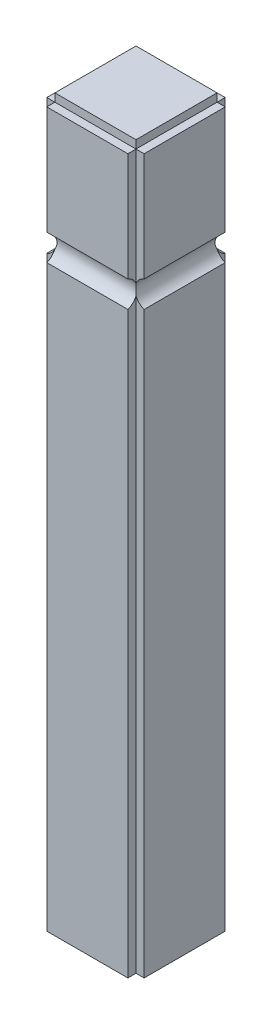
from build123d import *

# Parameters (mm, degrees)
SKETCH_4_W               = 180
SKETCH_4_H               = 180
EXTRUDE_1_DEPTH          = 1320
SKETCH_5_W               = 15
SKETCH_5_H               = 15
CUT_EXTRUDE_1_DEPTH      = 1320
CUT_EXTRUDE_2_DEPTH      = 1
CUT_EXTRUDE_2_DEPTH_BACK = 181
CUT_EXTRUDE_3_DEPTH      = 181
SKETCH_8_W               = 150
SKETCH_8_H               = 150
EXTRUDE_2_DEPTH          = 15


with BuildPart() as part:
    # 草图4 → 凸台-拉伸1 (new body)
    with BuildSketch(Plane(origin=(0, 0, 0), x_dir=(1, 0, 0), z_dir=(0, 1, 0))):
        with Locations((90, 90)):
            Rectangle(SKETCH_4_W, SKETCH_4_H)
    extrude(amount=-EXTRUDE_1_DEPTH)

    # 草图5 → 切除-拉伸1 (cut)
    with BuildSketch(Plane(origin=(0, 0, 0), x_dir=(1, 0, 0), z_dir=(0, 1, 0))):
        with Locations((7.5, 172.5)):
            Rectangle(SKETCH_5_W, SKETCH_5_H)
        with Locations((7.5, 7.5)):
            Rectangle(SKETCH_5_W, SKETCH_5_H)
        with Locations((172.5, 172.5)):
            Rectangle(SKETCH_5_W, SKETCH_5_H)
        with Locations((172.5, 7.5)):
            Rectangle(SKETCH_5_W, SKETCH_5_H)
    extrude(amount=-CUT_EXTRUDE_1_DEPTH, mode=Mode.SUBTRACT)

    # 草图6 → 切除-拉伸2 (cut, two sides)
    with BuildSketch(Plane.XY) as cut_extrude_2_sk:
        with BuildLine():
            Line((0, -200.607378165), (0, -249.392621835))
            ThreePointArc((0, -249.392621835), (17, -225), (0, -200.607378165))
        make_face()
        with BuildLine():
            Line((180, -200.607378165), (180, -249.392621835))
            ThreePointArc((180, -249.392621835), (163, -225), (180, -200.607378165))
        make_face()
    extrude(amount=CUT_EXTRUDE_2_DEPTH, mode=Mode.SUBTRACT)
    extrude(cut_extrude_2_sk.sketch, amount=-CUT_EXTRUDE_2_DEPTH_BACK, mode=Mode.SUBTRACT)

    # 草图7 → 切除-拉伸3 (cut, through all)
    with BuildSketch(Plane.ZY):
        with BuildLine():
            Line((-180, -200.607378165), (-180, -249.392621835))
            ThreePointArc((-180, -249.392621835), (-163, -225), (-180, -200.607378165))
        make_face()
        with BuildLine():
            Line((0, -200.607378165), (0, -249.392621835))
            ThreePointArc((0, -249.392621835), (-17, -225), (0, -200.607378165))
        make_face()
    extrude(amount=-CUT_EXTRUDE_3_DEPTH, mode=Mode.SUBTRACT)

    # 草图8 → 凸台-拉伸2 (add)
    with BuildSketch(Plane(origin=(0, 0, 0), x_dir=(1, 0, 0), z_dir=(0, 1, 0))):
        with Locations((90, 90)):
            Rectangle(SKETCH_8_W, SKETCH_8_H)
    extrude(amount=EXTRUDE_2_DEPTH)


solid = part.part
